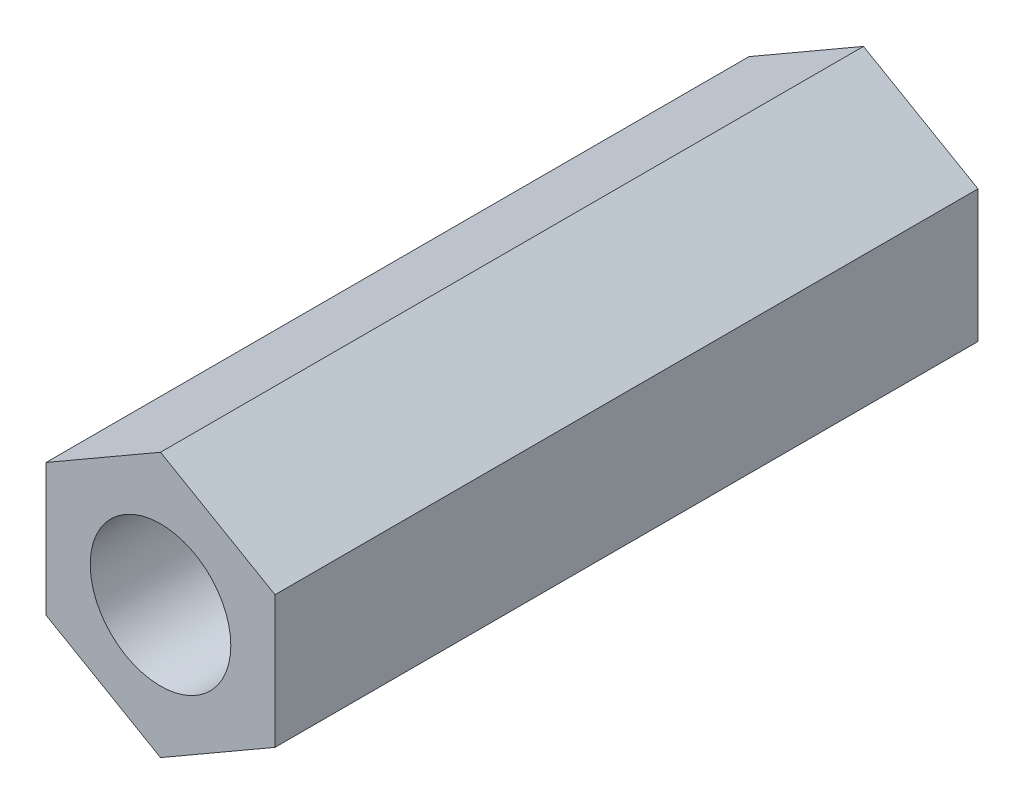
from build123d import *

# Parameters (mm, degrees)
SKETCH_1_R      = 1.5
EXTRUDE_1_DEPTH = 15


with BuildPart() as part:
    # 草图1 → 凸台-拉伸1 (new body)
    with BuildSketch(Plane.XY):
        Polygon((0, 2.82142964), (-2.443429743, 1.41071482), (-2.443429743, -1.41071482), (0, -2.82142964), (2.443429743, -1.41071482), (2.443429743, 1.41071482), align=None)
        Circle(SKETCH_1_R, mode=Mode.SUBTRACT)
    extrude(amount=EXTRUDE_1_DEPTH)


solid = part.part
